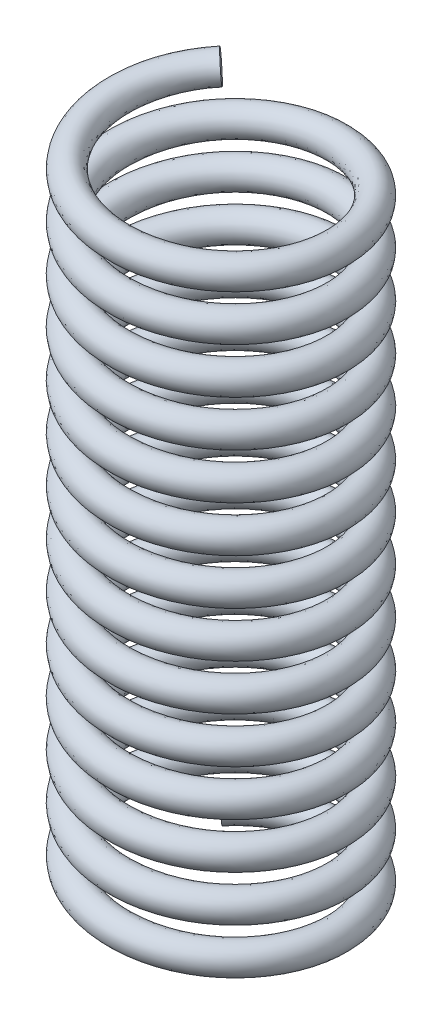
from build123d import *

# Parameters (mm, degrees)
SWEEP1_PITCH       = 1.571428571
SWEEP1_HEIGHT      = 22
SWEEP1_RADIUS      = 3.75
SWEEP1_START_ANGLE = -135
SWEEP1_PROFILE_R   = 0.5


with BuildPart() as part:
    # Sweep1: sweep along a helix
    with BuildLine() as sweep1_path:
        add(Helix(SWEEP1_PITCH, SWEEP1_HEIGHT, SWEEP1_RADIUS, center=(0, 0, 0), direction=(0, 1, 0), lefthand=True, mode=Mode.PRIVATE).rotate(Axis((0, 0, 0), (0, 1, 0)), SWEEP1_START_ANGLE))
    # Sweep1 profile (on start of the path) → Sweep1 (sweep)
    with BuildSketch(Plane(origin=(-2.651650429, 0, -2.651650429), x_dir=(0.707106781, 0, 0.707106781), z_dir=(0.705539394, 0.066545666, -0.705539394))):
        Circle(SWEEP1_PROFILE_R)
    sweep(path=sweep1_path.line, is_frenet=True)


solid = part.part
